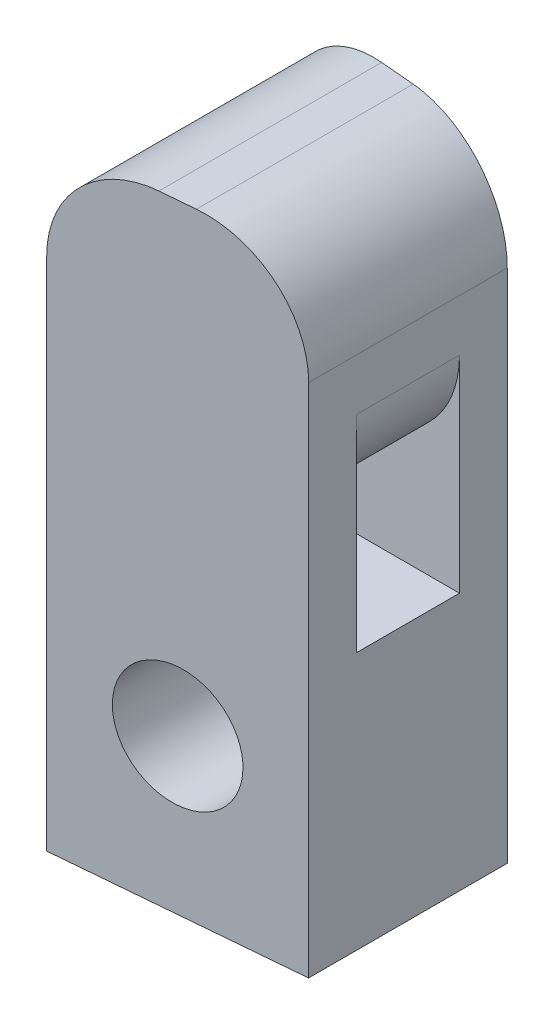
from build123d import *

# Parameters (mm, degrees)
BOSS_EXTRUDE1_DEPTH     = 10
BOSS_EXTRUDE2_DEPTH     = 2
SKETCH4_W               = 2
SKETCH4_H               = 2
CUT_EXTRUDE1_DEPTH      = 4.67
FILLET1_R               = 2
SKETCH6_R               = 1.165
CUT_EXTRUDE2_DEPTH      = 3.335
CUT_EXTRUDE2_DEPTH_BACK = 3.335


with BuildPart() as part:
    # Sketch2 → Boss-Extrude1 (new body)
    with BuildSketch(Plane(origin=(0, 0, 0), x_dir=(1, 0, 0), z_dir=(0, 1, 0))):
        Polygon((-2.335, -2.335), (-2.335, 2.335), (2.335, 1.926427941), (2.335, -1.926427941), align=None)
    extrude(amount=BOSS_EXTRUDE1_DEPTH)

    # Sketch3 → Boss-Extrude2 (add)
    with BuildSketch(Plane(origin=(0, 10, 0), x_dir=(1, 0, 0), z_dir=(0, 1, 0))):
        Polygon((2.335, -1.926427941), (2.335, 1.926427941), (-2.335, 2.335), (-2.335, -2.335), align=None)
    extrude(amount=BOSS_EXTRUDE2_DEPTH)

    # Sketch4 → Cut-Extrude1 (cut)
    with BuildSketch(Plane(origin=(2.335, 0, 0), x_dir=(0, 0, -1), z_dir=(1, 0, 0))):
        with Locations((0, 6)):
            Rectangle(SKETCH4_W, SKETCH4_H)
    extrude(amount=-CUT_EXTRUDE1_DEPTH, mode=Mode.SUBTRACT)

    # Fillet1
    fillet1_edges = [part.edges().sort_by_distance(p)[0] for p in [
        (2.335, 12, 0),
        (-2.335, 12, 0),
        (2.335, 7, 0),
        (-2.335, 7, 0),
    ]]
    fillet(fillet1_edges, radius=FILLET1_R)

    # Sketch6 → Cut-Extrude2 (cut, two sides)
    with BuildSketch(Plane.XY) as cut_extrude2_sk:
        with Locations((0, 3)):
            Circle(SKETCH6_R)
    extrude(amount=CUT_EXTRUDE2_DEPTH, mode=Mode.SUBTRACT)
    extrude(cut_extrude2_sk.sketch, amount=-CUT_EXTRUDE2_DEPTH_BACK, mode=Mode.SUBTRACT)


solid = part.part
